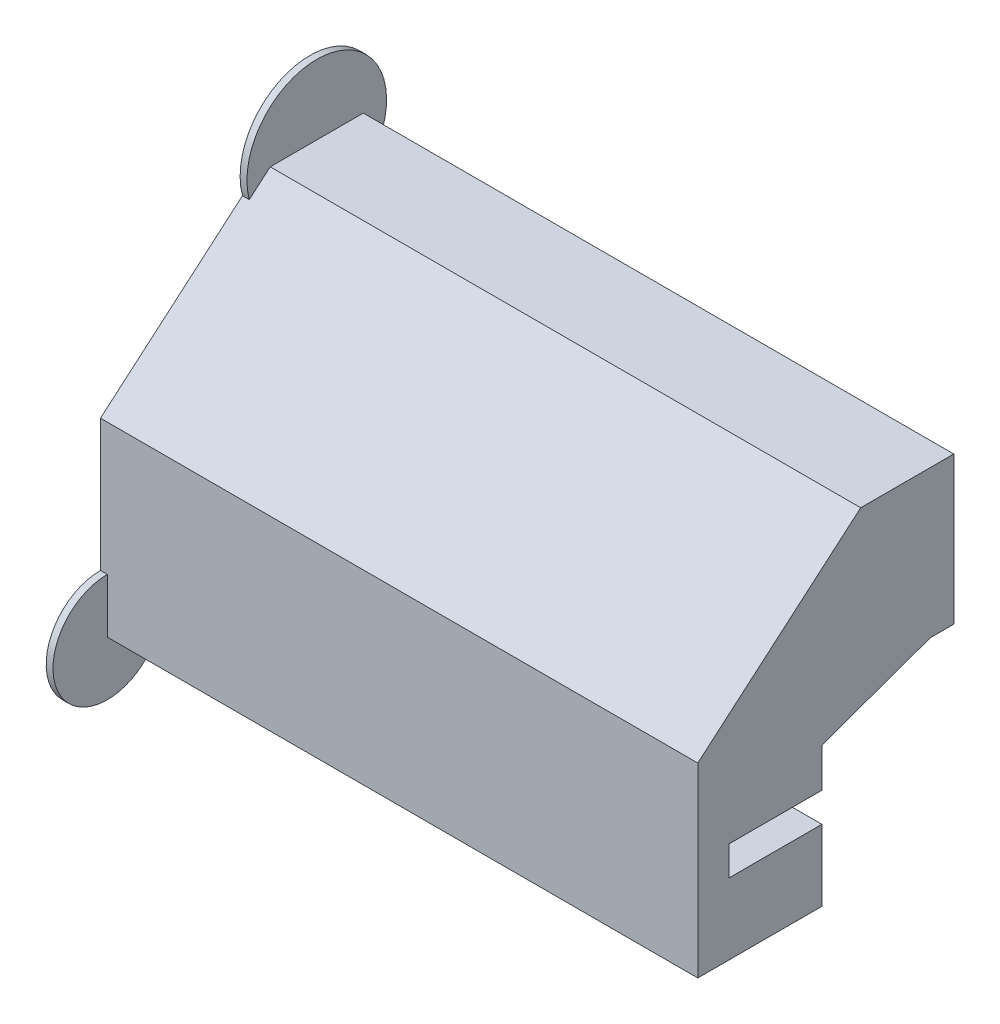
from build123d import *

# Parameters (mm, degrees)
SKETCH1_W           = 38.5
SKETCH1_H           = 21
BOSS_EXTRUDE1_DEPTH = 16.5
SKETCH2_R           = 1.7
CUT_EXTRUDE1_DEPTH  = 38.5
SKETCH2_5_R         = 1.7
SKETCH2_5_W         = 0.075
SKETCH2_5_H         = 3.377499074
SKETCH2_5_W_2       = 1.5
SKETCH2_5_H_2       = 4
CUT_EXTRUDE2_DEPTH  = 14.5
CUT_EXTRUDE3_START  = -16.5
SKETCH2_6_R         = 1.7
SKETCH2_6_W         = 0.075
SKETCH2_6_H         = 3.377499074
CUT_EXTRUDE3_DEPTH  = 2
CUT_EXTRUDE4_DEPTH  = 18
SKETCH4_R           = 1.3
CUT_EXTRUDE5_DEPTH  = 9.5
CUT_EXTRUDE7_DEPTH  = 6
CHAMFER3_SIZE       = 1
BOSS_EXTRUDE2_DEPTH = 0.44


with BuildPart() as part:
    # Sketch1 → Boss-Extrude1 (new body)
    with BuildSketch(Plane.XY):
        Rectangle(SKETCH1_W, SKETCH1_H)
    extrude(amount=BOSS_EXTRUDE1_DEPTH)

    # Sketch2 → Cut-Extrude1 (cut)
    with BuildSketch(Plane(origin=(19.25, 0, 0), x_dir=(0, 0, -1), z_dir=(1, 0, 0))):
        Polygon((-16.5, 10.5), (-16.5, 1.5), (-6, 10.5), align=None)
        with Locations((-5.5, -4.82)):
            Circle(SKETCH2_R)
    extrude(amount=-CUT_EXTRUDE1_DEPTH, mode=Mode.SUBTRACT)

    # Sketch2_5 → Cut-Extrude2 (cut)
    with BuildSketch(Plane(origin=(19.25, 0, 0), x_dir=(0, 0, -1), z_dir=(1, 0, 0))):
        Polygon((-8.5, -6.508749537), (-8.5, -10.5), (-1.5, -10.5), (-1.5, -6.5), (0, -6.5), (0, 1), (-1.5, 1), (-8.5, -1.5), (-8.5, -3.131250463), (-8.425, -3.131250463), (-5.5, -1.442500925), (-2.575, -3.131250463), (-2.575, -6.508749537), (-5.5, -8.197499075), (-8.425, -6.508749537), align=None)
        Polygon((-8.425, -6.508749537), (-5.5, -8.197499075), (-2.575, -6.508749537), (-2.575, -3.131250463), (-5.5, -1.442500925), (-8.425, -3.131250463), align=None)
        with Locations((-5.5, -4.82)):
            Circle(SKETCH2_5_R, mode=Mode.SUBTRACT)
        with Locations((-8.4625, -4.82)):
            Rectangle(SKETCH2_5_W, SKETCH2_5_H)
        with Locations((-0.75, -8.5)):
            Rectangle(SKETCH2_5_W_2, SKETCH2_5_H_2)
    extrude(amount=-CUT_EXTRUDE2_DEPTH, mode=Mode.SUBTRACT)

    # Sketch2_6 → Cut-Extrude3 (cut)
    with BuildSketch(Plane(origin=(19.25, 0, 0), x_dir=(0, 0, -1), z_dir=(1, 0, 0)).offset(CUT_EXTRUDE3_START)):
        Polygon((-8.425, -6.508749537), (-5.5, -8.197499075), (-2.575, -6.508749537), (-2.575, -3.131250463), (-5.5, -1.442500925), (-8.425, -3.131250463), align=None)
        with Locations((-5.5, -4.82)):
            Circle(SKETCH2_6_R, mode=Mode.SUBTRACT)
        with Locations((-5.5, -4.82)):
            Circle(SKETCH2_6_R)
        with Locations((-8.4625, -4.82)):
            Rectangle(SKETCH2_6_W, SKETCH2_6_H)
    extrude(amount=CUT_EXTRUDE3_DEPTH, mode=Mode.SUBTRACT)

    # Sketch3 → Cut-Extrude4 (cut)
    with BuildSketch(Plane.ZY.offset(19.25)):
        with BuildLine():
            Line((13.1, -8.92), (4.1, -8.92))
            ThreePointArc((4.1, -8.92), (2.685786438, -8.334213562), (2.1, -6.92))
            Line((2.1, -6.92), (2.1, -2.72))
            ThreePointArc((2.1, -2.72), (2.685786438, -1.305786438), (4.1, -0.72))
            Line((4.1, -0.72), (13.1, -0.72))
            ThreePointArc((13.1, -0.72), (14.514213562, -1.305786438), (15.1, -2.72))
            Line((15.1, -2.72), (15.1, -6.92))
            ThreePointArc((15.1, -6.92), (14.514213562, -8.334213562), (13.1, -8.92))
        make_face()
    extrude(amount=-CUT_EXTRUDE4_DEPTH, mode=Mode.SUBTRACT)

    # Sketch4 → Cut-Extrude5 (cut)
    with BuildSketch(Plane(origin=(0, 0, 0), x_dir=(-1, 0, 0), z_dir=(0, 0, -1))):
        with Locations((-6.75, 5)):
            Circle(SKETCH4_R)
        with Locations((6.75, 5)):
            Circle(SKETCH4_R)
    extrude(amount=-CUT_EXTRUDE5_DEPTH, mode=Mode.SUBTRACT)

    # Sketch5 → Cut-Extrude7 (cut)
    with BuildSketch(Plane(origin=(0, 0, 8.5), x_dir=(-1, 0, 0), z_dir=(0, 0, -1))):
        Polygon((-20.249996698, -5.92), (-4.75, -5.92), (-4.75, -4.253375074), (-4.90002704, -4.02), (-5.600019193, -4.02), (-6.050019814, -4.72), (-6.250019814, -4.72), (-6.450023117, -4.72), (-6.900023738, -4.02), (-7.600015891, -4.02), (-8.050016512, -4.72), (-8.250016512, -4.72), (-8.450019814, -4.72), (-8.900020436, -4.02), (-9.600012588, -4.02), (-10.05001321, -4.72), (-10.25001321, -4.72), (-10.450016512, -4.72), (-10.900017133, -4.02), (-11.600009286, -4.02), (-12.050009907, -4.72), (-12.250009907, -4.72), (-12.45001321, -4.72), (-12.900013831, -4.02), (-13.600005984, -4.02), (-14.050006605, -4.72), (-14.250006605, -4.72), (-14.450009907, -4.72), (-14.900010528, -4.02), (-15.600002681, -4.02), (-16.050003302, -4.72), (-16.250003302, -4.72), (-16.450006605, -4.72), (-16.900007226, -4.02), (-17.599999379, -4.02), (-18.05, -4.72), (-18.250003302, -4.72), (-18.450003302, -4.72), (-18.900003924, -4.02), (-19.599996076, -4.02), (-20.049996698, -4.72), (-20.249996698, -4.72), align=None)
    extrude(amount=-CUT_EXTRUDE7_DEPTH, mode=Mode.SUBTRACT)

    # Chamfer3
    chamfer3_edges = [part.edges().sort_by_distance(p)[0] for p in [
        (8.05, 5, 9.5),
        (-5.45, 5, 9.5),
    ]]
    chamfer(chamfer3_edges, length=CHAMFER3_SIZE)

    # Sketch6 → Boss-Extrude2 (add)
    with BuildSketch(Plane.ZY.offset(19.25)):
        with BuildLine():
            Line((4.1, -8.92), (4.1, -0.72))
            ThreePointArc((4.1, -0.72), (2.685786438, -1.305786438), (2.1, -2.72))
            Line((2.1, -2.72), (2.1, -6.92))
            ThreePointArc((2.1, -6.92), (2.685786438, -8.334213562), (4.1, -8.92))
        make_face()
        with BuildLine():
            ThreePointArc((15.1, -2.72), (14.514213562, -1.305786438), (13.1, -0.72))
            Line((13.1, -0.72), (13.1, -8.92))
            ThreePointArc((13.1, -8.92), (14.514213562, -8.334213562), (15.1, -6.92))
            Line((15.1, -6.92), (15.1, -2.72))
        make_face()
        with BuildLine():
            Line((16.5, -10.5), (13, -10.5))
            ThreePointArc((13, -10.5), (18.974873734, -12.974873734), (16.5, -7))
            Line((16.5, -7), (16.5, -10.5))
        make_face()
        with BuildLine():
            ThreePointArc((0, -7), (-2.474873734, -12.974873734), (3.5, -10.5))
            Line((3.5, -10.5), (0, -10.5))
            Line((0, -10.5), (0, -7))
        make_face()
        with BuildLine():
            ThreePointArc((7.348925314, 9.343778302), (1.710593433, 14.811314267), (0, 7.145898034))
            Line((0, 7.145898034), (0, 10.5))
            Line((0, 10.5), (6, 10.5))
            Line((6, 10.5), (7.348925314, 9.343778302))
        make_face()
    extrude(amount=-BOSS_EXTRUDE2_DEPTH)


solid = part.part
